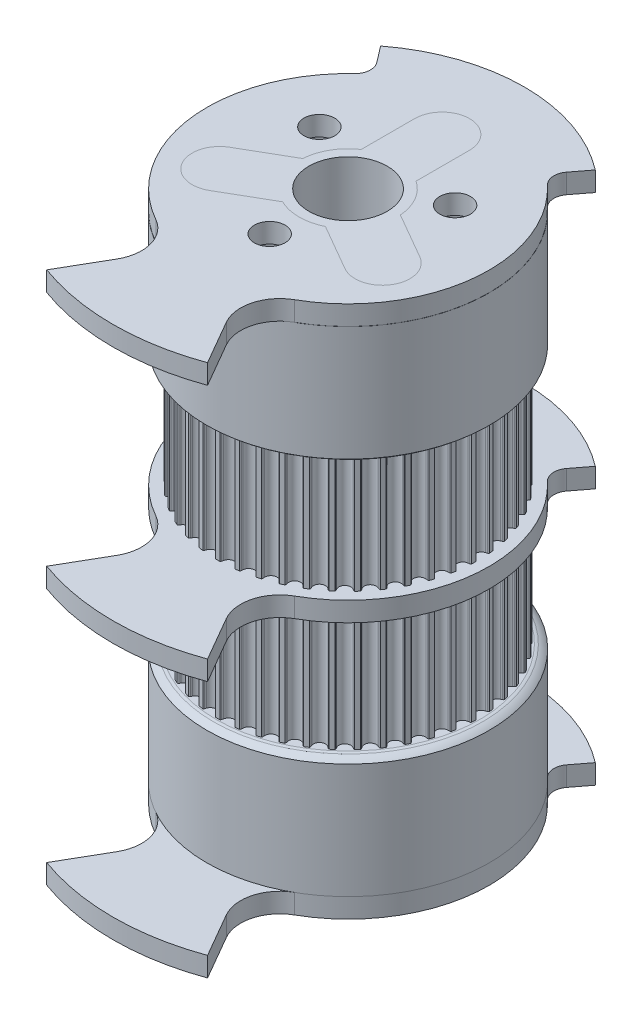
from build123d import *

# Parameters (mm, degrees)
SKETCH1_R               = 21.104918005
TOOTHOD_DEPTH           = 20.6375
TOOTHPROFILE_DEPTH      = 21.6375
TOOTHPATTERN_COUNT      = 45
SKETCH7_R               = 5.08
BORE_DEPTH              = 22.9075
BORE_DEPTH_BACK         = 22.9075
SKETCH9_R               = 22.882918005
SKETCH9_R_2             = 5.08
BOSS_EXTRUDE1_DEPTH     = 18.0975
SKETCH10_R              = 22.882918005
SKETCH10_R_2            = 5.08
BOSS_EXTRUDE2_DEPTH     = 13.0175
SKETCH11_R              = 4.7625
CUT_EXTRUDE1_DEPTH      = 75.93
CIRPATTERN1_COUNT       = 3
BOSS_EXTRUDE3_DEPTH     = 3.175
CIRPATTERN2_COUNT       = 3
SKETCH14_R              = 7.9375
SKETCH14_R_2            = 5.08
BOSS_EXTRUDE4_DEPTH     = 3.175
SKETCH12_R              = 6.35
CUT_EXTRUDE2_DEPTH      = 11.1125
SKETCH16_R              = 22.86
SKETCH16_R_2            = 2.4892
BOSS_EXTRUDE5_DEPTH     = 3.175
BOSS_EXTRUDE6_DEPTH     = 3.175
FILLET1_R               = 2.54
CUT_EXTRUDE3_START      = -22.882918
SKETCH18_W              = 45.76583601
SKETCH18_H              = 34.925
CUT_EXTRUDE3_DEPTH      = 45.765836
SKETCH20_W              = 45.76583601
SKETCH20_H              = 3.175
CUT_EXTRUDE4_DEPTH      = 23.882918005
CUT_EXTRUDE4_DEPTH_BACK = 23.882918005


with BuildPart() as part:
    # Sketch1 → ToothOD (new body, symmetric)
    with BuildSketch(Plane(origin=(0, 0, 0), x_dir=(1, 0, 0), z_dir=(0, 1, 0))):
        Circle(SKETCH1_R)
    extrude(amount=TOOTHOD_DEPTH, both=True)

    # Sketch2 → ToothProfile (cut, symmetric)
    with BuildSketch(Plane(origin=(0, 0, 0), x_dir=(1, 0, 0), z_dir=(0, 1, 0))):
        with BuildLine():
            ThreePointArc((-0.937033068, 20.654980001), (-0.590385173, 20.136805391), (0, 19.936518005))
            ThreePointArc((0, 19.936518005), (0.590385173, 20.136805391), (0.937033068, 20.654980001))
            ThreePointArc((0.937033068, 20.654980001), (0.971699064, 20.781091463), (1.007805813, 20.906798005))
            ThreePointArc((1.007805813, 20.906798005), (1.055402987, 21.001945002), (1.133238716, 21.074471144))
            ThreePointArc((1.133238716, 21.074471144), (0, 21.104918005), (-1.133238716, 21.074471144))
            ThreePointArc((-1.133238716, 21.074471144), (-1.055402987, 21.001945002), (-1.007805813, 20.906798005))
            ThreePointArc((-1.007805813, 20.906798005), (-0.971699064, 20.781091463), (-0.937033068, 20.654980001))
        make_face()
    toothprofile = extrude(amount=TOOTHPROFILE_DEPTH, both=True, mode=Mode.SUBTRACT)

    # ToothPattern: ToothProfile ×45 about axis
    toothpattern_axis = Axis((0, 0, 0), (0, 1, 0))
    for i in range(1, TOOTHPATTERN_COUNT):
        add(toothprofile.rotate(toothpattern_axis, i * 360 / TOOTHPATTERN_COUNT), mode=Mode.SUBTRACT)

    # Sketch4 → Flange (revolve)
    with BuildSketch(Plane.XY):
        with BuildLine():
            Line((0, -20.6375), (21.358918005, -20.6375))
            ThreePointArc((21.358918005, -20.6375), (21.588564626, -20.673451298), (21.813990333, -20.730137424))
            ThreePointArc((21.813990333, -20.730137424), (22.38171891, -21.011697125), (22.882918005, -21.3995))
            Line((22.882918005, -21.3995), (22.882918005, -21.9075))
            Line((22.882918005, -21.9075), (0, -21.9075))
            Line((0, -21.9075), (0, -20.6375))
        make_face()
        with BuildLine():
            Line((22.882918005, 21.9075), (22.882918005, 21.3995))
            ThreePointArc((22.882918005, 21.3995), (22.38171891, 21.011697125), (21.813990333, 20.730137424))
            ThreePointArc((21.813990333, 20.730137424), (21.588564626, 20.673451298), (21.358918005, 20.6375))
            Line((21.358918005, 20.6375), (0, 20.6375))
            Line((0, 20.6375), (0, 21.9075))
            Line((0, 21.9075), (22.882918005, 21.9075))
        make_face()
    revolve(axis=Axis((0, 8.73125, 0), (0, -1, 0)))

    # Sketch7 → Bore (cut, two sides)
    with BuildSketch(Plane.XZ) as bore_sk:
        Circle(SKETCH7_R)
    extrude(amount=BORE_DEPTH, mode=Mode.SUBTRACT)
    extrude(bore_sk.sketch, amount=-BORE_DEPTH_BACK, mode=Mode.SUBTRACT)

    # Sketch9 → Boss-Extrude1 (add)
    with BuildSketch(Plane.XZ.offset(21.9075)):
        Circle(SKETCH9_R)
        Circle(SKETCH9_R_2, mode=Mode.SUBTRACT)
    extrude(amount=BOSS_EXTRUDE1_DEPTH)

    # Sketch10 → Boss-Extrude2 (add)
    with BuildSketch(Plane(origin=(0, 21.9075, 0), x_dir=(1, 0, 0), z_dir=(0, 1, 0))):
        Circle(SKETCH10_R)
        Circle(SKETCH10_R_2, mode=Mode.SUBTRACT)
    extrude(amount=BOSS_EXTRUDE2_DEPTH)

    # Sketch11 → Cut-Extrude1 (cut, through all)
    with BuildSketch(Plane.XZ.offset(40.005)):
        with Locations((0, 12.7)):
            Circle(SKETCH11_R)
    cut_extrude1 = extrude(amount=-CUT_EXTRUDE1_DEPTH, mode=Mode.SUBTRACT)

    # CirPattern1: Cut-Extrude1 ×3 about axis
    cirpattern1_axis = Axis((0, 0, 0), (0, 1, 0))
    for i in range(1, CIRPATTERN1_COUNT):
        add(cut_extrude1.rotate(cirpattern1_axis, i * 360 / CIRPATTERN1_COUNT), mode=Mode.SUBTRACT)

    # Sketch13 → Boss-Extrude3 (add)
    with BuildSketch(Plane.XZ.offset(40.005)):
        with BuildLine():
            Line((-0.092645251, 5.079155132), (10.975727154, 11.46948292))
            ThreePointArc((10.975727154, 11.46948292), (17.047710073, 9.8425), (15.420727154, 3.77051708))
            Line((15.420727154, 3.77051708), (4.352354749, -2.619810707))
            ThreePointArc((4.352354749, -2.619810707), (4.399409051, 2.54), (-0.092645251, 5.079155132))
        make_face()
    boss_extrude3 = extrude(amount=BOSS_EXTRUDE3_DEPTH)

    # CirPattern2: Boss-Extrude3 ×3 about axis
    cirpattern2_axis = Axis((0, 0, 0), (0, 1, 0))
    for i in range(1, CIRPATTERN2_COUNT):
        add(boss_extrude3.rotate(cirpattern2_axis, i * 360 / CIRPATTERN2_COUNT))

    # Sketch14 → Boss-Extrude4 (add)
    with BuildSketch(Plane.XZ.offset(40.005)):
        Circle(SKETCH14_R)
        Circle(SKETCH14_R_2, mode=Mode.SUBTRACT)
    extrude(amount=BOSS_EXTRUDE4_DEPTH)

    # Sketch12 → Cut-Extrude2 (cut)
    with BuildSketch(Plane.XZ.offset(43.18)):
        Circle(SKETCH12_R)
    extrude(amount=-CUT_EXTRUDE2_DEPTH, mode=Mode.SUBTRACT)

    # Sketch18 → Cut-Extrude3 (cut)
    with BuildSketch(Plane(origin=(0, 0, 0), x_dir=(0, 0, -1), z_dir=(1, 0, 0)).offset(CUT_EXTRUDE3_START)):
        with Locations((0, 17.4625)):
            Rectangle(SKETCH18_W, SKETCH18_H)
    extrude(amount=CUT_EXTRUDE3_DEPTH, mode=Mode.SUBTRACT)


with BuildPart() as body_2:
    # Sketch16 → Boss-Extrude5 (new body)
    with BuildSketch(Plane.XZ.offset(40.005)):
        Circle(SKETCH16_R)
        with Locations((0, 12.7)):
            Circle(SKETCH16_R_2, mode=Mode.SUBTRACT)
        with Locations((10.998522628, -6.35)):
            Circle(SKETCH16_R_2, mode=Mode.SUBTRACT)
        with Locations((-10.998522628, -6.35)):
            Circle(SKETCH16_R_2, mode=Mode.SUBTRACT)
        with BuildLine():
            Line((4.445, -6.576160069), (4.445, -15.24))
            ThreePointArc((4.445, -15.24), (0, -19.685), (-4.445, -15.24))
            Line((-4.445, -15.24), (-4.445, -6.576160069))
            ThreePointArc((-4.445, -6.576160069), (-5.807755231, -5.410534671), (-6.874076643, -3.96875))
            ThreePointArc((-6.874076643, -3.96875), (-7.589538089, -2.324396234), (-7.917621679, -0.561402885))
            Line((-7.917621679, -0.561402885), (-15.420727154, 3.77051708))
            ThreePointArc((-15.420727154, 3.77051708), (-17.047710073, 9.8425), (-10.975727154, 11.46948292))
            Line((-10.975727154, 11.46948292), (-3.472621679, 7.137562954))
            ThreePointArc((-3.472621679, 7.137562954), (-1.781782857, 7.734930905), (0, 7.9375))
            ThreePointArc((0, 7.9375), (1.781782857, 7.734930905), (3.472621679, 7.137562954))
            Line((3.472621679, 7.137562954), (10.975727154, 11.46948292))
            ThreePointArc((10.975727154, 11.46948292), (17.047710073, 9.8425), (15.420727154, 3.77051708))
            Line((15.420727154, 3.77051708), (7.917621679, -0.561402885))
            ThreePointArc((7.917621679, -0.561402885), (7.589538089, -2.324396234), (6.874076643, -3.96875))
            ThreePointArc((6.874076643, -3.96875), (5.807755231, -5.410534671), (4.445, -6.576160069))
        make_face(mode=Mode.SUBTRACT)
    extrude(amount=BOSS_EXTRUDE5_DEPTH)

    # Sketch17 → Boss-Extrude6 (add)
    with BuildSketch(Plane.XZ.offset(43.18)):
        with BuildLine():
            Line((-13.030967461, 35.802288852), (-8.874774193, 28.603550946))
            ThreePointArc((-8.874774193, 28.603550946), (-8.24795329, 23.757139367), (-11.24924518, 19.900605089))
            ThreePointArc((-11.24924518, 19.900605089), (0, 22.86), (11.24924518, 19.900605089))
            ThreePointArc((11.24924518, 19.900605089), (8.24795329, 23.757139367), (8.874774193, 28.603550946))
            Line((8.874774193, 28.603550946), (13.030967461, 35.802288852))
            ThreePointArc((13.030967461, 35.802288852), (0, 38.1), (-13.030967461, 35.802288852))
        make_face()
        with BuildLine():
            Line((-17.395357834, -22.670071699), (-13.916286267, -18.136057359))
            ThreePointArc((-13.916286267, -18.136057359), (0, -22.86), (13.916286267, -18.136057359))
            Line((13.916286267, -18.136057359), (17.395357834, -22.670071699))
            ThreePointArc((17.395357834, -22.670071699), (0, -28.575), (-17.395357834, -22.670071699))
        make_face()
    extrude(amount=-BOSS_EXTRUDE6_DEPTH)

    # Fillet1
    fillet1_edges = [body_2.edges().sort_by_distance(p)[0] for p in [
        (-13.916286267, -41.5925, -18.136057359),
        (13.916286267, -41.5925, -18.136057359),
    ]]
    fillet(fillet1_edges, radius=FILLET1_R)


with BuildPart() as body_3:
    # Mirror6: mirrored copy
    add(part.part.mirror(Plane.ZX))


with BuildPart() as body_4:
    # Mirror6 2: mirrored copy
    add(body_2.part.mirror(Plane.ZX))


with BuildPart() as cut_extrude4_tool:
    # Sketch20 → Cut-Extrude4 (new body, two sides)
    with BuildSketch(Plane(origin=(0, 0, 0), x_dir=(0, 0, -1), z_dir=(1, 0, 0))) as cut_extrude4_sk:
        Rectangle(SKETCH20_W, SKETCH20_H)
    extrude(amount=CUT_EXTRUDE4_DEPTH)
    extrude(cut_extrude4_sk.sketch, amount=-CUT_EXTRUDE4_DEPTH_BACK)


with BuildPart() as part_1:
    add(part.part)

    # Cut-Extrude4: cut by cut_extrude4_tool
    add(cut_extrude4_tool.part, mode=Mode.SUBTRACT)


with BuildPart() as body_3_1:
    add(body_3.part)

    # Cut-Extrude4: cut by cut_extrude4_tool
    add(cut_extrude4_tool.part, mode=Mode.SUBTRACT)


with BuildPart() as body_5:
    # Mirror7: mirrored copy
    add(body_2.part.mirror(Plane.ZX.offset(-20.79625)))


solid = Compound([body_2.part, body_4.part, part_1.part, body_3_1.part, body_5.part])
